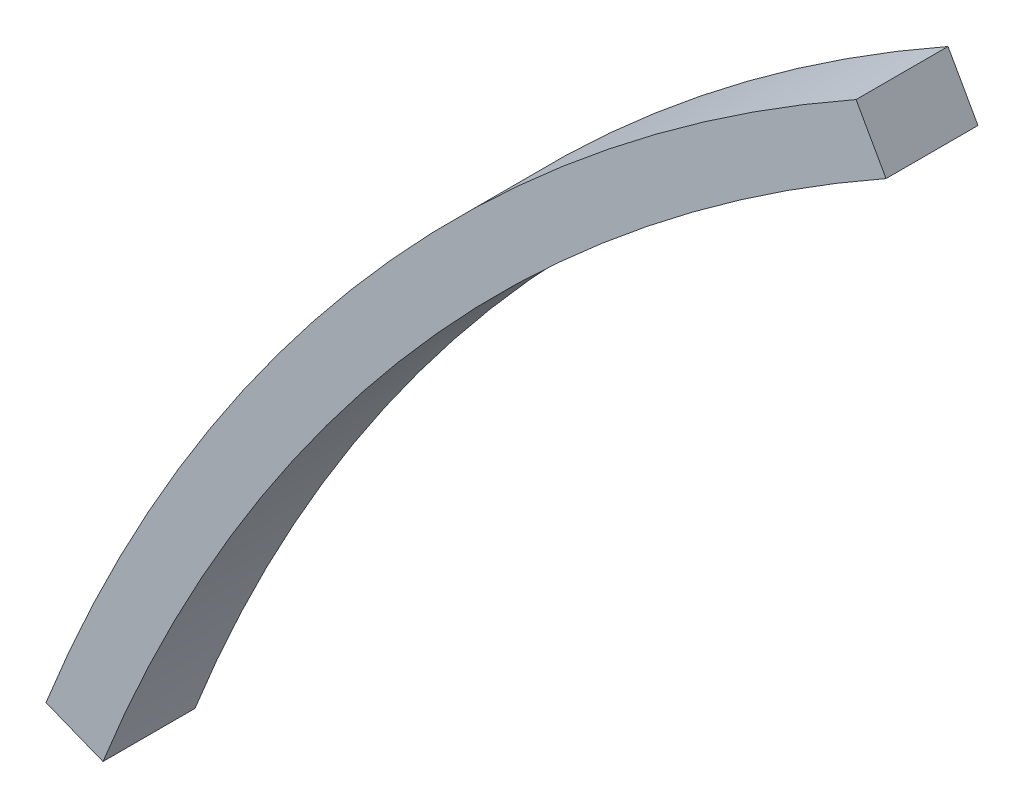
from build123d import *

# Parameters (mm, degrees)
BOSS_EXTRUDE1_DEPTH = 3


with BuildPart() as part:
    # Sketch1 → Boss-Extrude1 (new body)
    with BuildSketch(Plane.XY):
        with BuildLine():
            Line((-53.93452077, 21.332310454), (-55.794331831, 22.067907366))
            ThreePointArc((-55.794331831, 22.067907366), (-45.186321015, 39.473996417), (-29.363032686, 52.32410832))
            Line((-29.363032686, 52.32410832), (-28.38426493, 50.579971376))
            ThreePointArc((-28.38426493, 50.579971376), (-43.680110315, 38.158196536), (-53.93452077, 21.332310454))
        make_face()
    extrude(amount=BOSS_EXTRUDE1_DEPTH)


solid = part.part
